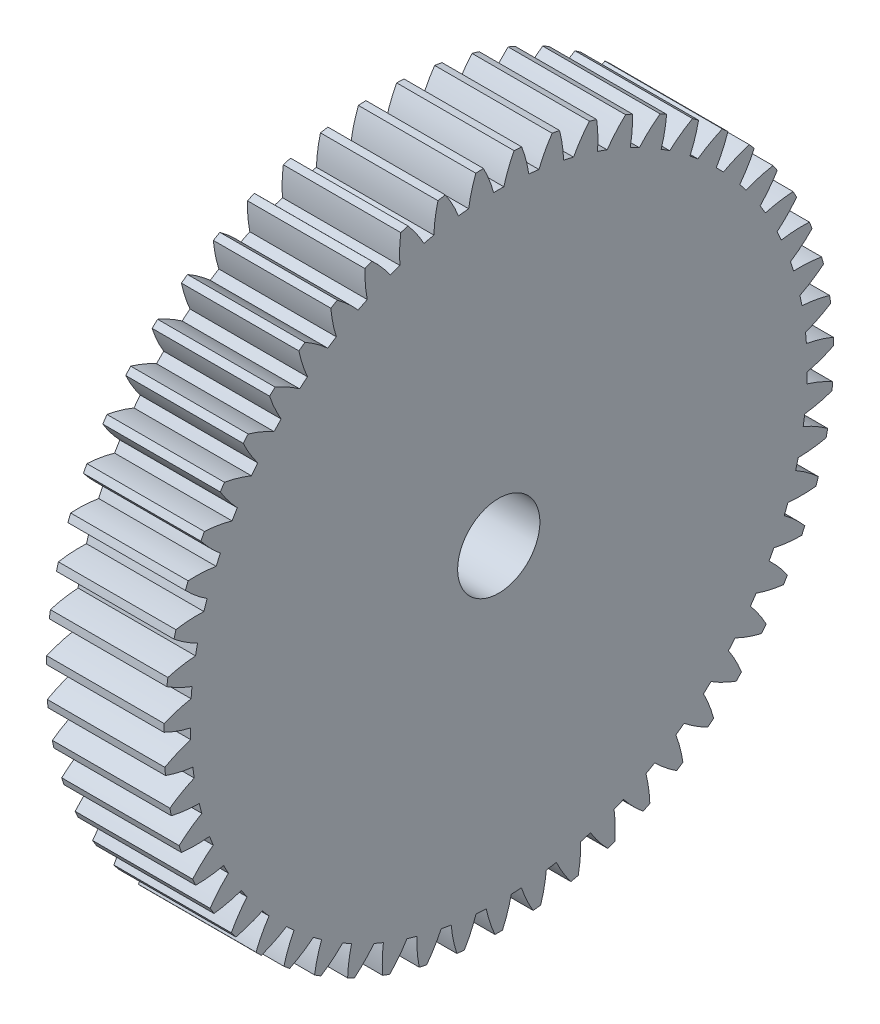
from build123d import *

# Parameters (mm, degrees)
BASPROSKE_W     = 10
BASPROSKE_H     = 28.5
TOOTHCUT_DEPTH  = 42.527099586
TEETHCUTS_COUNT = 55
TEETHCUTS_ANGLE = 353.454545455
BORSKE_R        = 3.5
BORE_DEPTH      = 50.0000508


with BuildPart() as part:
    # BasProSke → Base-Revolve (revolve)
    with BuildSketch(Plane(origin=(0, 0, 0), x_dir=(1, 0, 0), z_dir=(0, 1, 0)), mode=Mode.PRIVATE) as base_revolve_sk:
        with Locations((5, 14.25)):
            Rectangle(BASPROSKE_W, BASPROSKE_H)
    revolve(base_revolve_sk.sketch.rotate(Axis((-10, 0, 0), (1, 0, 0)), 180), axis=Axis((-10, 0, 0), (1, 0, 0)))

    # TooCutSke → ToothCut (cut, through all)
    with BuildSketch(Plane(origin=(0, 0, 0), x_dir=(0, 0, -1), z_dir=(1, 0, 0))):
        with BuildLine():
            ThreePointArc((0.433583944, 26.245418761), (0, 26.249), (-0.433583944, 26.245418761))
            ThreePointArc((-0.433583944, 26.245418761), (-0.814942664, 27.394560811), (-1.320285506, 28.494829204))
            ThreePointArc((-1.320285506, 28.494829204), (0, 28.5254), (1.320285506, 28.494829204))
            ThreePointArc((1.320285506, 28.494829204), (0.814942664, 27.394560811), (0.433583944, 26.245418761))
        make_face()
    toothcut = extrude(amount=TOOTHCUT_DEPTH, mode=Mode.SUBTRACT)

    # TeethCuts: ToothCut ×55 about axis
    teethcuts_axis = Axis((-10, 0, 0), (1, 0, 0))
    for i in range(1, TEETHCUTS_COUNT):
        add(toothcut.rotate(teethcuts_axis, i * TEETHCUTS_ANGLE / (TEETHCUTS_COUNT - 1)), mode=Mode.SUBTRACT)

    # BorSke → Bore (cut, symmetric)
    with BuildSketch(Plane(origin=(0, 0, 0), x_dir=(0, 0, -1), z_dir=(1, 0, 0))):
        with Locations(Location((0, 0, 0), (0, 0, 180))):
            Circle(BORSKE_R)
    extrude(amount=BORE_DEPTH, both=True, mode=Mode.SUBTRACT)


solid = part.part
